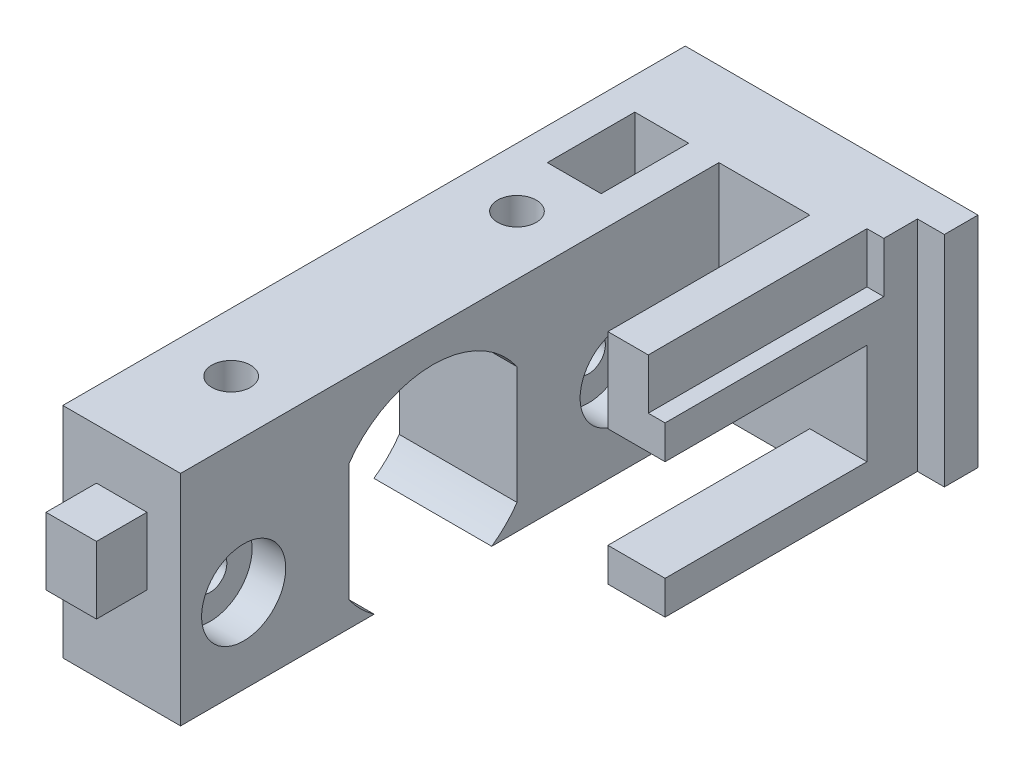
from build123d import *

# Parameters (mm, degrees)
SKETCH2_R           = 1
BOSS_EXTRUDE1_DEPTH = 7
CUT_EXTRUDE1_START  = -5
SKETCH3_R           = 1.15
CUT_EXTRUDE1_DEPTH  = 13
SKETCH5_R           = 2.5
CUT_EXTRUDE2_DEPTH  = 2
CUT_EXTRUDE3_START  = 7
SKETCH5_2_R         = 2.5
CUT_EXTRUDE3_DEPTH  = 2
BOSS_EXTRUDE2_START = -5
BOSS_EXTRUDE2_DEPTH = 13
CUT_EXTRUDE4_START  = 17.4
SKETCH7_W           = 12
SKETCH7_H           = 6
CUT_EXTRUDE4_DEPTH  = 6
CUT_EXTRUDE5_START  = 17.4
SKETCH8_W           = 15
SKETCH8_H           = 13
CUT_EXTRUDE5_DEPTH  = 1.6
CUT_EXTRUDE6_START  = 15.8
SKETCH9_W           = 13
SKETCH9_H           = 3
CUT_EXTRUDE6_DEPTH  = 1
BOSS_EXTRUDE3_START = 8
SKETCH10_W          = 5.4
SKETCH10_H          = 5
BOSS_EXTRUDE3_DEPTH = 13
CUT_EXTRUDE7_START  = 8
SKETCH11_W          = 17.4
SKETCH11_H          = 3
CUT_EXTRUDE7_DEPTH  = 13
BOSS_EXTRUDE4_START = 15
SKETCH12_W          = 3
SKETCH12_H          = 4
BOSS_EXTRUDE4_DEPTH = 3
CUT_EXTRUDE8_START  = 8
SKETCH13_W          = 3.2
SKETCH13_H          = 5.2
CUT_EXTRUDE8_DEPTH  = 3.2


with BuildPart() as part:
    # Sketch2 → Boss-Extrude1 (new body)
    with BuildSketch(Plane(origin=(0, 0, 0), x_dir=(0, 0, -1), z_dir=(1, 0, 0))):
        with BuildLine():
            Line((3.494281042, -5), (15, -5))
            Line((15, -5), (15, 8))
            Line((15, 8), (-15, 8))
            Line((-15, 8), (-15, -5))
            Line((-15, -5), (-3.494281042, -5))
            ThreePointArc((-3.494281042, -5), (-4.313351365, -4.313351365), (-5, -3.494281042))
            Line((-5, -3.494281042), (-5, 3.494281042))
            ThreePointArc((-5, 3.494281042), (0, 6.1), (5, 3.494281042))
            Line((5, 3.494281042), (5, -3.494281042))
            ThreePointArc((5, -3.494281042), (4.313351365, -4.313351365), (3.494281042, -5))
        make_face()
        with Locations((-11.25, 0)):
            Circle(SKETCH2_R, mode=Mode.SUBTRACT)
        with Locations((11.25, 0)):
            Circle(SKETCH2_R, mode=Mode.SUBTRACT)
    extrude(amount=BOSS_EXTRUDE1_DEPTH)

    # Sketch3 → Cut-Extrude1 (cut)
    with BuildSketch(Plane(origin=(0, 0, 0), x_dir=(1, 0, 0), z_dir=(0, 1, 0)).offset(CUT_EXTRUDE1_START)):
        with Locations((3.5, 8.494281042)):
            Circle(SKETCH3_R)
        with Locations((3.5, -8.494281042)):
            Circle(SKETCH3_R)
    extrude(amount=CUT_EXTRUDE1_DEPTH, mode=Mode.SUBTRACT)

    # Sketch5 → Cut-Extrude2 (cut)
    with BuildSketch(Plane(origin=(0, 0, 0), x_dir=(0, 0, -1), z_dir=(1, 0, 0))):
        with Locations((11.25, 0)):
            Circle(SKETCH5_R)
        with Locations((-11.25, 0)):
            Circle(SKETCH5_R)
    extrude(amount=CUT_EXTRUDE2_DEPTH, mode=Mode.SUBTRACT)

    # Sketch5_2 → Cut-Extrude3 (cut)
    with BuildSketch(Plane(origin=(0, 0, 0), x_dir=(0, 0, -1), z_dir=(1, 0, 0)).offset(CUT_EXTRUDE3_START)):
        with Locations((11.25, 0)):
            Circle(SKETCH5_2_R)
        with Locations((-11.25, 0)):
            Circle(SKETCH5_2_R)
    extrude(amount=-CUT_EXTRUDE3_DEPTH, mode=Mode.SUBTRACT)

    # Sketch6 → Boss-Extrude2 (add)
    with BuildSketch(Plane(origin=(0, 0, 0), x_dir=(1, 0, 0), z_dir=(0, 1, 0)).offset(BOSS_EXTRUDE2_START)):
        Polygon((0, 15), (7, 15), (7, 22), (12.4, 22), (12.4, 5), (17.4, 5), (17.4, 25), (0, 25), align=None)
    extrude(amount=BOSS_EXTRUDE2_DEPTH)

    # Sketch7 → Cut-Extrude4 (cut)
    with BuildSketch(Plane(origin=(0, 0, 0), x_dir=(0, 0, -1), z_dir=(1, 0, 0)).offset(CUT_EXTRUDE4_START)):
        with Locations((11, 0)):
            Rectangle(SKETCH7_W, SKETCH7_H)
    extrude(amount=-CUT_EXTRUDE4_DEPTH, mode=Mode.SUBTRACT)

    # Sketch8 → Cut-Extrude5 (cut)
    with BuildSketch(Plane(origin=(0, 0, 0), x_dir=(0, 0, -1), z_dir=(1, 0, 0)).offset(CUT_EXTRUDE5_START)):
        with Locations((12.5, 1.5)):
            Rectangle(SKETCH8_W, SKETCH8_H)
    extrude(amount=-CUT_EXTRUDE5_DEPTH, mode=Mode.SUBTRACT)

    # Sketch9 → Cut-Extrude6 (cut)
    with BuildSketch(Plane(origin=(0, 0, 0), x_dir=(0, 0, -1), z_dir=(1, 0, 0)).offset(CUT_EXTRUDE6_START)):
        with Locations((11.5, 6.5)):
            Rectangle(SKETCH9_W, SKETCH9_H)
    extrude(amount=-CUT_EXTRUDE6_DEPTH, mode=Mode.SUBTRACT)

    # Sketch10 → Boss-Extrude3 (add)
    with BuildSketch(Plane(origin=(0, 0, 0), x_dir=(1, 0, 0), z_dir=(0, 1, 0)).offset(BOSS_EXTRUDE3_START)):
        with Locations((9.7, 19.5)):
            Rectangle(SKETCH10_W, SKETCH10_H)
    extrude(amount=-BOSS_EXTRUDE3_DEPTH)

    # Sketch11 → Cut-Extrude7 (cut)
    with BuildSketch(Plane(origin=(0, 0, 0), x_dir=(1, 0, 0), z_dir=(0, 1, 0)).offset(CUT_EXTRUDE7_START)):
        with Locations((8.7, 23.5)):
            Rectangle(SKETCH11_W, SKETCH11_H)
    extrude(amount=-CUT_EXTRUDE7_DEPTH, mode=Mode.SUBTRACT)

    # Sketch12 → Boss-Extrude4 (add)
    with BuildSketch(Plane.XY.offset(BOSS_EXTRUDE4_START)):
        with Locations((3.5, 3)):
            Rectangle(SKETCH12_W, SKETCH12_H)
    extrude(amount=BOSS_EXTRUDE4_DEPTH)

    # Sketch13 → Cut-Extrude8 (cut)
    with BuildSketch(Plane(origin=(0, 0, 0), x_dir=(1, 0, 0), z_dir=(0, 1, 0)).offset(CUT_EXTRUDE8_START)):
        with Locations((3.5, 14.5)):
            Rectangle(SKETCH13_W, SKETCH13_H)
    extrude(amount=-CUT_EXTRUDE8_DEPTH, mode=Mode.SUBTRACT)


solid = part.part
